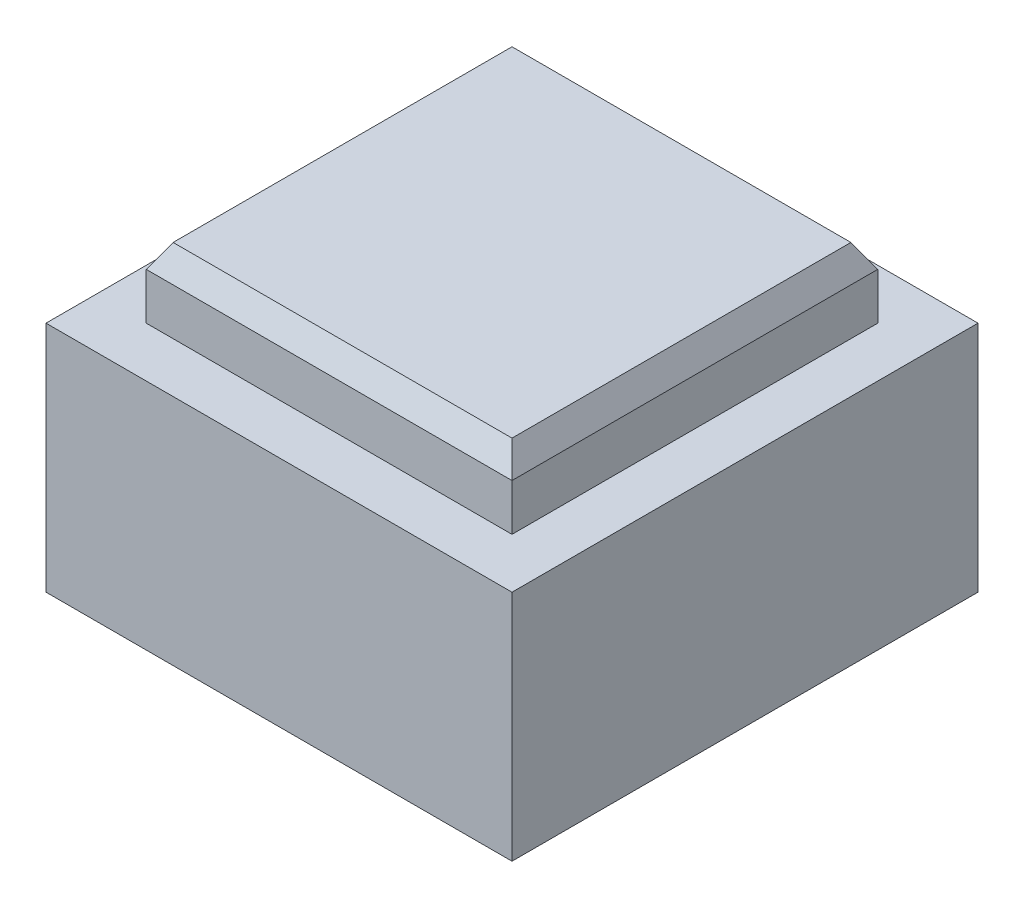
from build123d import *

# Parameters (mm, degrees)
SKETCH1_W             = 20
SKETCH1_H             = 20
BOSS_EXTRUDE1_DEPTH   = 10
SKETCH2_W             = 15.7
SKETCH2_H             = 15.7
BOSS_EXTRUDE2_DEPTH   = 3
CHAMFER1_SIZE         = 1
CHAMFER1_SIZE2        = 0.577350269
CHAMFER1_PART_2_SIZE  = 1
CHAMFER1_PART_2_SIZE2 = 0.577350269
CHAMFER1_PART_3_SIZE  = 1
CHAMFER1_PART_3_SIZE2 = 0.577350269
CHAMFER1_PART_4_SIZE  = 1
CHAMFER1_PART_4_SIZE2 = 0.577350269
CUT_EXTRUDE1_DEPTH    = 8
CHAMFER2_SIZE         = 1
CHAMFER2_SIZE2        = 2.747477419


with BuildPart() as part:
    # Sketch1 → Boss-Extrude1 (new body)
    with BuildSketch(Plane(origin=(0, 0, 0), x_dir=(1, 0, 0), z_dir=(0, 1, 0))):
        Rectangle(SKETCH1_W, SKETCH1_H)
    extrude(amount=BOSS_EXTRUDE1_DEPTH)

    # Sketch2 → Boss-Extrude2 (add)
    with BuildSketch(Plane(origin=(0, 10, 0), x_dir=(1, 0, 0), z_dir=(0, 1, 0))):
        Rectangle(SKETCH2_W, SKETCH2_H)
    extrude(amount=BOSS_EXTRUDE2_DEPTH)

    # Chamfer1
    chamfer1_edges = [part.edges().sort_by_distance(p)[0] for p in [
        (-7.85, 13, 0),
    ]]
    chamfer1_side = [part.faces().sort_by_distance(p)[0] for p in [
        (-7.85, 11.5, 0),
    ]]
    chamfer(chamfer1_edges, length=CHAMFER1_SIZE, length2=CHAMFER1_SIZE2, reference=chamfer1_side[0])

    # Chamfer1 part 2
    chamfer1_part_2_edges = [part.edges().sort_by_distance(p)[0] for p in [
        (0, 13, 7.85),
    ]]
    chamfer1_part_2_side = [part.faces().sort_by_distance(p)[0] for p in [
        (0, 11.5, 7.85),
    ]]
    chamfer(chamfer1_part_2_edges, length=CHAMFER1_PART_2_SIZE, length2=CHAMFER1_PART_2_SIZE2, reference=chamfer1_part_2_side[0])

    # Chamfer1 part 3
    chamfer1_part_3_edges = [part.edges().sort_by_distance(p)[0] for p in [
        (7.85, 13, 0),
    ]]
    chamfer1_part_3_side = [part.faces().sort_by_distance(p)[0] for p in [
        (7.85, 11.5, 0),
    ]]
    chamfer(chamfer1_part_3_edges, length=CHAMFER1_PART_3_SIZE, length2=CHAMFER1_PART_3_SIZE2, reference=chamfer1_part_3_side[0])

    # Chamfer1 part 4
    chamfer1_part_4_edges = [part.edges().sort_by_distance(p)[0] for p in [
        (0, 13, -7.85),
    ]]
    chamfer1_part_4_side = [part.faces().sort_by_distance(p)[0] for p in [
        (0, 11.5, -7.85),
    ]]
    chamfer(chamfer1_part_4_edges, length=CHAMFER1_PART_4_SIZE, length2=CHAMFER1_PART_4_SIZE2, reference=chamfer1_part_4_side[0])

    # Sketch3 → Cut-Extrude1 (cut)
    with BuildSketch(Plane.XZ):
        Polygon((-3.7, 6.408587988), (-7.4, 0), (-3.7, -6.408587988), (3.7, -6.408587988), (7.4, 0), (3.7, 6.408587988), align=None)
    extrude(amount=-CUT_EXTRUDE1_DEPTH, mode=Mode.SUBTRACT)

    # Chamfer2
    chamfer2_edges = [part.edges().sort_by_distance(p)[0] for p in [
        (0, 0, 6.408587988),
        (-5.55, 0, 3.204293994),
        (-5.55, 0, -3.204293994),
        (0, 0, -6.408587988),
        (5.55, 0, -3.204293994),
        (5.55, 0, 3.204293994),
    ]]
    chamfer2_side = [part.faces().sort_by_distance(p)[0] for p in [
        (0, 0, 9.717157288),
    ]]
    chamfer(chamfer2_edges, length=CHAMFER2_SIZE, length2=CHAMFER2_SIZE2, reference=chamfer2_side[0])


solid = part.part
